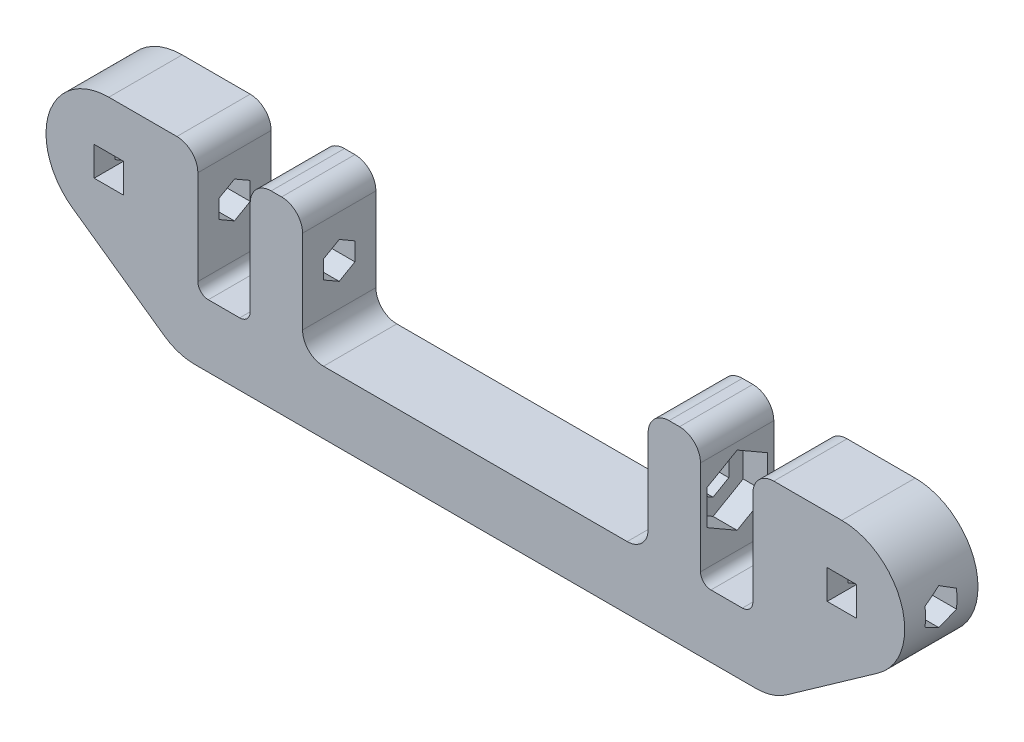
from build123d import *

# Parameters (mm, degrees)
SKETCH1_W               = 2.8
SKETCH1_H               = 2.8
BOSS_EXTRUDE1_DEPTH     = 3.5
CUT_EXTRUDE1_DEPTH      = 43.86315434
CUT_EXTRUDE1_DEPTH_BACK = 43.86315434
CUT_EXTRUDE2_DEPTH      = 2.3
FILLET1_R               = 2
FILLET2_R               = 5
FILLET3_R               = 1


with BuildPart() as part:
    # Sketch1 → Boss-Extrude1 (new, symmetric)
    with BuildSketch(Plane.XY):
        with BuildLine():
            Line((16.5, 0), (-16.5, 0))
            Line((-16.5, 0), (-16.5, 12))
            Line((-16.5, 12), (-21.5, 12))
            Line((-21.5, 12), (-21.5, 0))
            Line((-21.5, 0), (-26.5, 0))
            Line((-26.5, 0), (-26.5, 12))
            Line((-26.5, 12), (-35, 12))
            ThreePointArc((-35, 12), (-40.718865407, 7.81509737), (-38.460099186, 1.09819282))
            Line((-38.460099186, 1.09819282), (-28.404326023, -6))
            Line((-28.404326023, -6), (28.404326023, -6))
            Line((28.404326023, -6), (38.460099186, 1.09819282))
            ThreePointArc((38.460099186, 1.09819282), (40.718865407, 7.81509737), (35, 12))
            Line((35, 12), (26.5, 12))
            Line((26.5, 12), (26.5, 0))
            Line((26.5, 0), (21.5, 0))
            Line((21.5, 0), (21.5, 12))
            Line((21.5, 12), (16.5, 12))
            Line((16.5, 12), (16.5, 0))
        make_face()
        with Locations((35, 6)):
            Rectangle(SKETCH1_W, SKETCH1_H, mode=Mode.SUBTRACT)
        with Locations((-35, 6)):
            Rectangle(SKETCH1_W, SKETCH1_H, mode=Mode.SUBTRACT)
    extrude(amount=BOSS_EXTRUDE1_DEPTH, both=True)

    # Sketch2 → Cut-Extrude1 (cut, two sides: drawn at the far end of the back side and taken through both)
    with BuildSketch(Plane.ZY.offset(-CUT_EXTRUDE1_DEPTH_BACK)):
        Polygon((0, 7.732050808), (-1.5, 6.866025404), (-1.5, 5.133974596), (0, 4.267949192), (1.5, 5.133974596), (1.5, 6.866025404), align=None)
    extrude(amount=CUT_EXTRUDE1_DEPTH + CUT_EXTRUDE1_DEPTH_BACK, mode=Mode.SUBTRACT)

    # Sketch3 → Cut-Extrude2 (cut)
    with BuildSketch(Plane.ZY.offset(21.5)):
        Polygon((2.875, 7.659882024), (0, 9.319764048), (-2.875, 7.659882024), (-2.875, 4.340117976), (0, 2.680235952), (2.875, 4.340117976), align=None)
    cut_extrude2 = extrude(amount=-CUT_EXTRUDE2_DEPTH, mode=Mode.SUBTRACT)

    # Mirror1: Cut-Extrude2 across plane
    add(cut_extrude2.mirror(Plane(origin=(0, 0, 0), x_dir=(0, 0, 1), z_dir=(1, 0, 0))), mode=Mode.SUBTRACT)

    # Fillet1
    fillet1_edges = [part.edges().sort_by_distance(p)[0] for p in [
        (-16.5, 0, 0),
        (16.5, 0, 0),
        (-26.5, 12, 0),
        (26.5, 12, 0),
        (21.5, 12, 0),
        (16.5, 12, 0),
        (-21.5, 12, 0),
        (-16.5, 12, 0),
    ]]
    fillet(fillet1_edges, radius=FILLET1_R)

    # Fillet2
    fillet2_edges = [part.edges().sort_by_distance(p)[0] for p in [
        (28.404326023, -6, 0),
        (-28.404326023, -6, 0),
    ]]
    fillet(fillet2_edges, radius=FILLET2_R)

    # Fillet3
    fillet3_edges = [part.edges().sort_by_distance(p)[0] for p in [
        (26.5, 0, 0),
        (21.5, 0, 0),
        (-26.5, 0, 0),
        (-21.5, 0, 0),
    ]]
    fillet(fillet3_edges, radius=FILLET3_R)


solid = part.part
